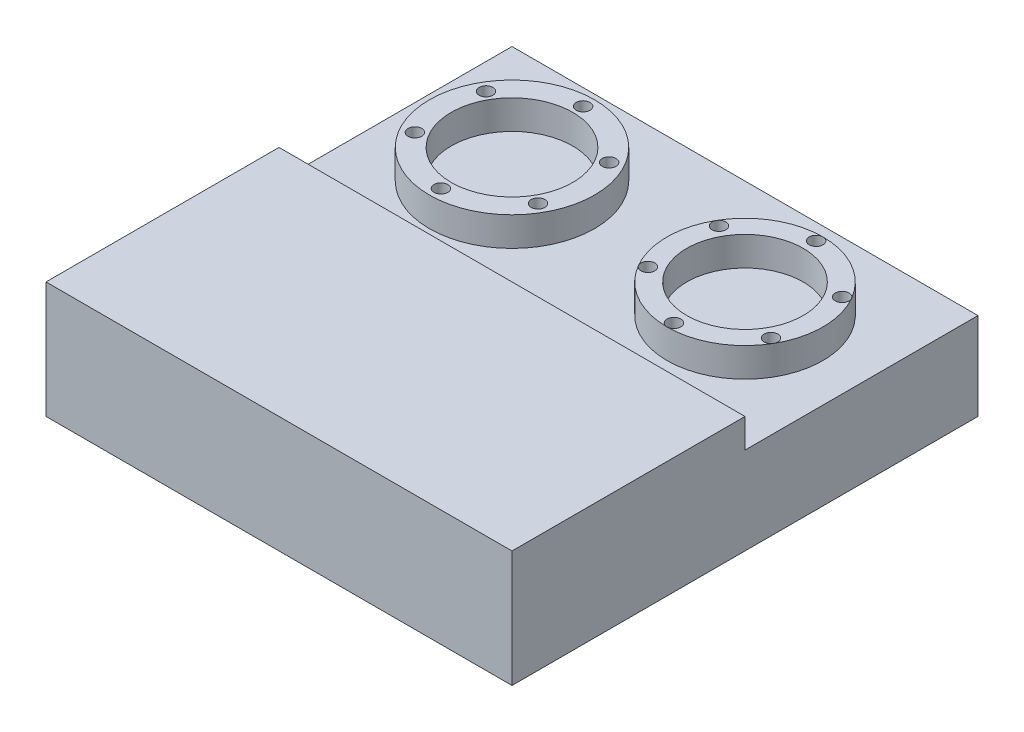
from build123d import *

# Parameters (mm, degrees)
SKETCH1_W           = 101.6
SKETCH1_H           = 101.6
BOSS_EXTRUDE1_DEPTH = 19.05
SKETCH2_R           = 18
SKETCH2_R_2         = 1.5
SKETCH2_R_3         = 13.25
SKETCH2_R_4         = 17.005
SKETCH2_R_5         = 12.7
BOSS_EXTRUDE2_DEPTH = 6.35
SKETCH3_W           = 101.6
SKETCH3_H           = 50.8
BOSS_EXTRUDE3_DEPTH = 6.35


with BuildPart() as part:
    # Sketch1 → Boss-Extrude1 (new body)
    with BuildSketch(Plane(origin=(0, 0, 0), x_dir=(1, 0, 0), z_dir=(0, 1, 0))):
        Rectangle(SKETCH1_W, SKETCH1_H)
    extrude(amount=BOSS_EXTRUDE1_DEPTH)

    # Sketch2 → Boss-Extrude2 (add)
    with BuildSketch(Plane(origin=(0, 19.05, 0), x_dir=(1, 0, 0), z_dir=(0, 1, 0))):
        with Locations((-25.4, 25.4)):
            Circle(SKETCH2_R)
        with Locations((-38.823393759, 33.15)):
            Circle(SKETCH2_R_2, mode=Mode.SUBTRACT)
        with Locations((-38.823393759, 17.65)):
            Circle(SKETCH2_R_2, mode=Mode.SUBTRACT)
        with Locations((-25.4, 9.9)):
            Circle(SKETCH2_R_2, mode=Mode.SUBTRACT)
        with Locations((-11.976606241, 17.65)):
            Circle(SKETCH2_R_2, mode=Mode.SUBTRACT)
        with Locations((-11.976606241, 33.15)):
            Circle(SKETCH2_R_2, mode=Mode.SUBTRACT)
        with Locations((-25.4, 40.9)):
            Circle(SKETCH2_R_2, mode=Mode.SUBTRACT)
        with Locations((-25.4, 25.4)):
            Circle(SKETCH2_R_3, mode=Mode.SUBTRACT)
        with Locations((25.4, 25.4)):
            Circle(SKETCH2_R_4)
        with Locations((11.976606241, 33.15)):
            Circle(SKETCH2_R_2, mode=Mode.SUBTRACT)
        with Locations((11.976606241, 17.65)):
            Circle(SKETCH2_R_2, mode=Mode.SUBTRACT)
        with Locations((25.4, 9.9)):
            Circle(SKETCH2_R_2, mode=Mode.SUBTRACT)
        with Locations((38.823393759, 17.65)):
            Circle(SKETCH2_R_2, mode=Mode.SUBTRACT)
        with Locations((38.823393759, 33.15)):
            Circle(SKETCH2_R_2, mode=Mode.SUBTRACT)
        with Locations((25.4, 40.9)):
            Circle(SKETCH2_R_2, mode=Mode.SUBTRACT)
        with Locations((25.4, 25.4)):
            Circle(SKETCH2_R_5, mode=Mode.SUBTRACT)
    extrude(amount=BOSS_EXTRUDE2_DEPTH)

    # Sketch3 → Boss-Extrude3 (add)
    with BuildSketch(Plane(origin=(0, 19.05, 0), x_dir=(1, 0, 0), z_dir=(0, 1, 0))):
        with Locations((0, -25.4)):
            Rectangle(SKETCH3_W, SKETCH3_H)
    extrude(amount=BOSS_EXTRUDE3_DEPTH)


solid = part.part
